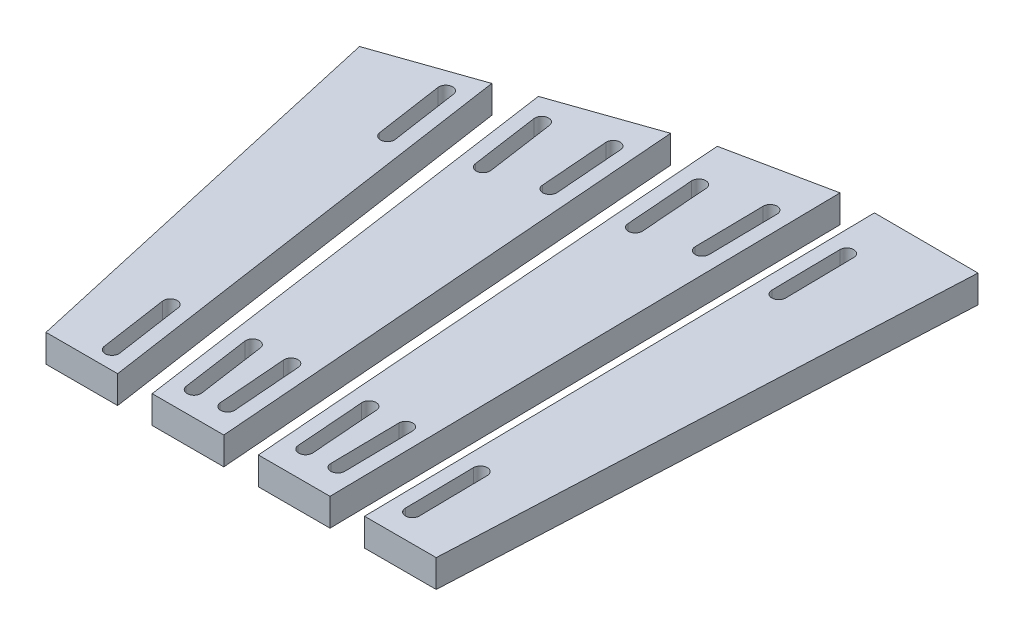
from build123d import *

# Parameters (mm, degrees)
BOSS_EXTRUDE1_DEPTH   = 4
BOSS_EXTRUDE1_2_DEPTH = 4
BOSS_EXTRUDE1_3_DEPTH = 4
BOSS_EXTRUDE1_4_DEPTH = 4
CUT_EXTRUDE1_DEPTH    = 5


with BuildPart() as part:
    # Sketch3 → Boss-Extrude1 (new body)
    with BuildSketch(Plane(origin=(0, 0, 0), x_dir=(1, 0, 0), z_dir=(0, 1, 0))):
        Polygon((-47.213729066, 21.042060041), (-33.007188918, 25.994229451), (-23.691598112, -37.5), (-34.067352907, -37.5), align=None)
    extrude(amount=BOSS_EXTRUDE1_DEPTH)


with BuildPart() as body_2:
    # Sketch3 → Boss-Extrude1 2 (new body)
    with BuildSketch(Plane(origin=(0, 0, 0), x_dir=(1, 0, 0), z_dir=(0, 1, 0))):
        Polygon((-28.007188918, 27.737148331), (-13.800648769, 32.68931774), (-8.315843317, -37.5), (-18.691598112, -37.5), align=None)
    extrude(amount=BOSS_EXTRUDE1_2_DEPTH)


with BuildPart() as body_3:
    # Sketch3 → Boss-Extrude1 3 (new body)
    with BuildSketch(Plane(origin=(0, 0, 0), x_dir=(1, 0, 0), z_dir=(0, 1, 0))):
        Polygon((22.435666272, -37.5), (12.059911477, -37.5), (10.932152609, 37.464795247), (25.976999486, 37.416346408), align=None)
    extrude(amount=BOSS_EXTRUDE1_3_DEPTH)


with BuildPart() as body_4:
    # Sketch3 → Boss-Extrude1 4 (new body)
    with BuildSketch(Plane(origin=(0, 0, 0), x_dir=(1, 0, 0), z_dir=(0, 1, 0))):
        Polygon((-8.800648769, 34.43223662), (5.932152609, 37.480896721), (7.059911477, -37.5), (-3.315843317, -37.5), align=None)
    extrude(amount=BOSS_EXTRUDE1_4_DEPTH)


with BuildPart() as cut_extrude1_tool:
    # Sketch4 → Cut-Extrude1 (new body, through all)
    with BuildSketch(Plane(origin=(0, 0, 0), x_dir=(1, 0, 0), z_dir=(0, 1, 0))):
        with BuildLine():
            Line((-34.42457978, 21.877283541), (-32.972964435, 11.983203852))
            ThreePointArc((-32.972964435, 11.983203852), (-33.81721087, 10.848634349), (-34.951780373, 11.692880783))
            Line((-34.951780373, 11.692880783), (-36.403395718, 21.586960472))
            ThreePointArc((-36.403395718, 21.586960472), (-35.559149283, 22.721529976), (-34.42457978, 21.877283541))
        make_face()
        with BuildLine():
            Line((-27.56726282, -24.861572382), (-26.115647475, -34.75565207))
            ThreePointArc((-26.115647475, -34.75565207), (-26.959893909, -35.890221574), (-28.094463413, -35.045975139))
            Line((-28.094463413, -35.045975139), (-29.546078757, -25.15189545))
            ThreePointArc((-29.546078757, -25.15189545), (-28.701832323, -24.017325947), (-27.56726282, -24.861572382))
        make_face()
        with BuildLine():
            Line((-23.56343255, 24.913669754), (-22.14981411, 15.014089819))
            ThreePointArc((-22.14981411, 15.014089819), (-22.99841026, 13.882769981), (-24.129730097, 14.731366131))
            Line((-24.129730097, 14.731366131), (-25.543348537, 24.630946067))
            ThreePointArc((-25.543348537, 24.630946067), (-24.694752387, 25.762265904), (-23.56343255, 24.913669754))
        make_face()
        with BuildLine():
            Line((-16.58829251, -23.933285303), (-15.17467407, -33.832865239))
            ThreePointArc((-15.17467407, -33.832865239), (-16.02327022, -34.964185076), (-17.154590057, -34.115588927))
            Line((-17.154590057, -34.115588927), (-18.568208497, -24.216008991))
            ThreePointArc((-18.568208497, -24.216008991), (-17.719612347, -23.084689153), (-16.58829251, -23.933285303))
        make_face()
        with BuildLine():
            Line((-15.363012646, 27.01084324), (-14.583957383, 17.04123578))
            ThreePointArc((-14.583957383, 17.04123578), (-15.503012603, 15.966369508), (-16.577878875, 16.885424728))
            Line((-16.577878875, 16.885424728), (-17.356934138, 26.855032187))
            ThreePointArc((-17.356934138, 26.855032187), (-16.437878918, 27.929898459), (-15.363012646, 27.01084324))
        make_face()
        with BuildLine():
            Line((-11.408077758, -23.600647707), (-10.629022496, -33.570255167))
            ThreePointArc((-10.629022496, -33.570255167), (-11.548077715, -34.645121439), (-12.622943988, -33.726066219))
            Line((-12.622943988, -33.726066219), (-13.40199925, -23.75645876))
            ThreePointArc((-13.40199925, -23.75645876), (-12.48294403, -22.681592488), (-11.408077758, -23.600647707))
        make_face()
        with BuildLine():
            Line((-4.326785443, 28.36988258), (-3.566496238, 18.398826451))
            ThreePointArc((-3.566496238, 18.398826451), (-4.48757293, 17.325691917), (-5.560707464, 18.24676861))
            Line((-5.560707464, 18.24676861), (-6.320996669, 28.217824738))
            ThreePointArc((-6.320996669, 28.217824738), (-5.399919976, 29.290959272), (-4.326785443, 28.36988258))
        make_face()
        with BuildLine():
            Line((4.04031749, 30.274337554), (4.190723649, 20.274337554))
            ThreePointArc((4.190723649, 20.274337554), (3.205875655, 19.259411729), (2.190949831, 20.244259724))
            Line((2.190949831, 20.244259724), (2.040543672, 30.244259724))
            ThreePointArc((2.040543672, 30.244259724), (3.025391666, 31.259185548), (4.04031749, 30.274337554))
        make_face()
        with BuildLine():
            Line((-0.385810436, -23.315295538), (0.374478769, -33.286351667))
            ThreePointArc((0.374478769, -33.286351667), (-0.546597923, -34.359486201), (-1.619732457, -33.438409508))
            Line((-1.619732457, -33.438409508), (-2.380021662, -23.467353379))
            ThreePointArc((-2.380021662, -23.467353379), (-1.45894497, -22.394218846), (-0.385810436, -23.315295538))
        make_face()
        with BuildLine():
            Line((4.846078374, -23.297995449), (4.996484533, -33.297995449))
            ThreePointArc((4.996484533, -33.297995449), (4.011636539, -34.312921273), (2.996710715, -33.328073278))
            Line((2.996710715, -33.328073278), (2.846304556, -23.328073278))
            ThreePointArc((2.846304556, -23.328073278), (3.83115255, -22.313147454), (4.846078374, -23.297995449))
        make_face()
        with BuildLine():
            Line((15.039358693, 30.368639682), (15.189797157, 20.368639682))
            ThreePointArc((15.189797157, 20.368639682), (14.204952441, 19.353710677), (13.190023436, 20.338555394))
            Line((13.190023436, 20.338555394), (13.039584972, 30.338555394))
            ThreePointArc((13.039584972, 30.338555394), (14.024429688, 31.353484399), (15.039358693, 30.368639682))
        make_face()
        with BuildLine():
            Line((15.849707318, -23.497147154), (16.000145783, -33.497147154))
            ThreePointArc((16.000145783, -33.497147154), (15.015301067, -34.512076159), (14.000372062, -33.527231443))
            Line((14.000372062, -33.527231443), (13.849933597, -23.527231443))
            ThreePointArc((13.849933597, -23.527231443), (14.834778313, -22.512302438), (15.849707318, -23.497147154))
        make_face()
    extrude(amount=CUT_EXTRUDE1_DEPTH)


with BuildPart() as part_1:
    add(part.part)

    # Cut-Extrude1: cut by cut_extrude1_tool
    add(cut_extrude1_tool.part, mode=Mode.SUBTRACT)


with BuildPart() as body_2_1:
    add(body_2.part)

    # Cut-Extrude1: cut by cut_extrude1_tool
    add(cut_extrude1_tool.part, mode=Mode.SUBTRACT)


with BuildPart() as body_3_1:
    add(body_3.part)

    # Cut-Extrude1: cut by cut_extrude1_tool
    add(cut_extrude1_tool.part, mode=Mode.SUBTRACT)


with BuildPart() as body_4_1:
    add(body_4.part)

    # Cut-Extrude1: cut by cut_extrude1_tool
    add(cut_extrude1_tool.part, mode=Mode.SUBTRACT)


solid = Compound([part_1.part, body_2_1.part, body_3_1.part, body_4_1.part])
